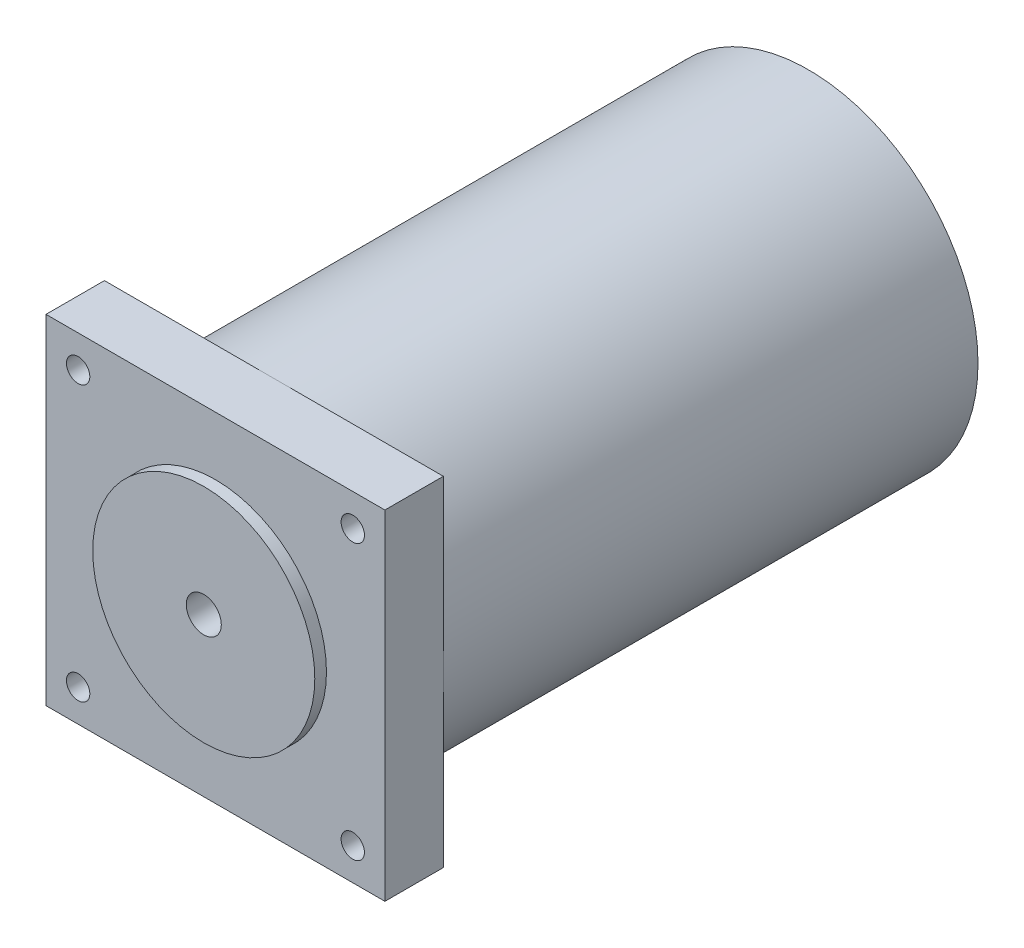
from build123d import *

# Parameters (mm, degrees)
SKETCH1_R           = 19
BOSS_EXTRUDE1_DEPTH = 2
SKETCH3_W           = 58
SKETCH3_H           = 58
BOSS_EXTRUDE2_DEPTH = 10
SKETCH4_R           = 29
BOSS_EXTRUDE3_DEPTH = 91.5
SKETCH5_R           = 2
CUT_EXTRUDE1_DEPTH  = 10
SKETCH6_R           = 3
CUT_EXTRUDE2_DEPTH  = 12


with BuildPart() as part:
    # Sketch1 → Boss-Extrude1 (new body)
    with BuildSketch(Plane.XY):
        Circle(SKETCH1_R)
    extrude(amount=-BOSS_EXTRUDE1_DEPTH)

    # Sketch3 → Boss-Extrude2 (add)
    with BuildSketch(Plane(origin=(0, 0, -2), x_dir=(-1, 0, 0), z_dir=(0, 0, -1))):
        Rectangle(SKETCH3_W, SKETCH3_H)
    extrude(amount=BOSS_EXTRUDE2_DEPTH)

    # Sketch4 → Boss-Extrude3 (add)
    with BuildSketch(Plane(origin=(0, 0, -12), x_dir=(-1, 0, 0), z_dir=(0, 0, -1))):
        Circle(SKETCH4_R)
    extrude(amount=BOSS_EXTRUDE3_DEPTH)

    # Sketch5 → Cut-Extrude1 (cut)
    with BuildSketch(Plane.XY.offset(-2)):
        with Locations((-23.5, 23.5)):
            Circle(SKETCH5_R)
        with Locations((23.5, 23.5)):
            Circle(SKETCH5_R)
        with Locations((23.5, -23.5)):
            Circle(SKETCH5_R)
        with Locations((-23.5, -23.5)):
            Circle(SKETCH5_R)
    extrude(amount=-CUT_EXTRUDE1_DEPTH, mode=Mode.SUBTRACT)

    # Sketch6 → Cut-Extrude2 (cut)
    with BuildSketch(Plane.XY):
        Circle(SKETCH6_R)
    extrude(amount=-CUT_EXTRUDE2_DEPTH, mode=Mode.SUBTRACT)


solid = part.part
